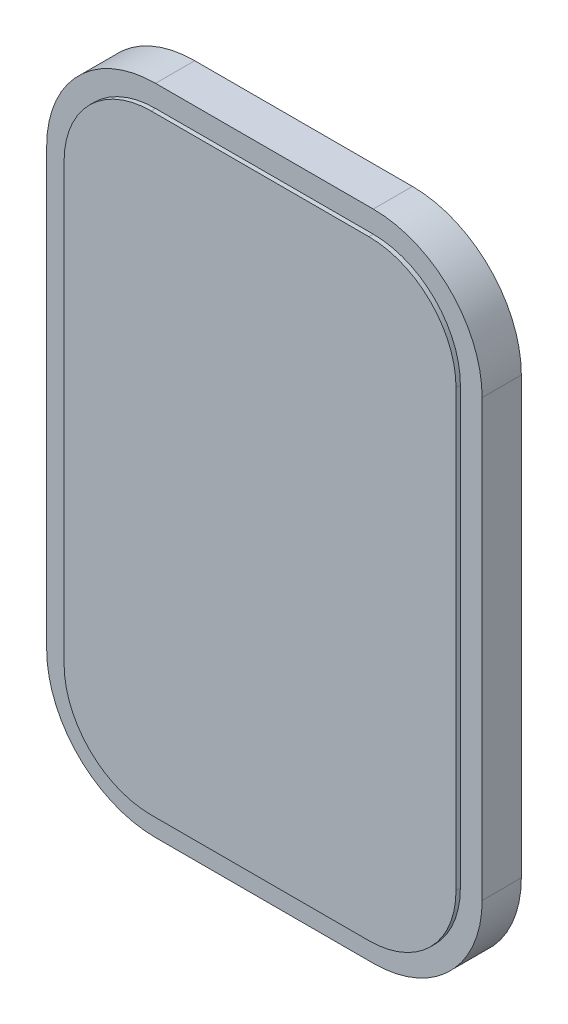
from build123d import *

# Parameters (mm, degrees)
SKETCH1_W           = 25.4
SKETCH1_H           = 38.1
BOSS_EXTRUDE1_DEPTH = 2.54
FILLET1_R           = 6.35
CUT_EXTRUDE1_DEPTH  = 0.254


with BuildPart() as part:
    # Sketch1 → Boss-Extrude1 (new body)
    with BuildSketch(Plane.XY):
        Rectangle(SKETCH1_W, SKETCH1_H)
    extrude(amount=BOSS_EXTRUDE1_DEPTH)

    # Fillet1
    fillet1_edges = [part.edges().sort_by_distance(p)[0] for p in [
        (12.7, -19.05, 1.27),
        (-12.7, -19.05, 1.27),
        (-12.7, 19.05, 1.27),
        (12.7, 19.05, 1.27),
    ]]
    fillet(fillet1_edges, radius=FILLET1_R)

    # Sketch2 → Cut-Extrude1 (cut)
    with BuildSketch(Plane.XY.offset(2.54)):
        with BuildLine():
            Line((-6.35, -19.05), (6.35, -19.05))
            ThreePointArc((6.35, -19.05), (10.840128061, -17.190128061), (12.7, -12.7))
            Line((12.7, -12.7), (12.7, 12.7))
            ThreePointArc((12.7, 12.7), (10.840128061, 17.190128061), (6.35, 19.05))
            Line((6.35, 19.05), (-6.35, 19.05))
            ThreePointArc((-6.35, 19.05), (-10.840128061, 17.190128061), (-12.7, 12.7))
            Line((-12.7, 12.7), (-12.7, -12.7))
            ThreePointArc((-12.7, -12.7), (-10.840128061, -17.190128061), (-6.35, -19.05))
        make_face()
        with BuildLine():
            Line((-11.43, 12.7), (-11.43, -12.7))
            ThreePointArc((-11.43, -12.7), (-9.942102448, -16.292102448), (-6.35, -17.78))
            Line((-6.35, -17.78), (6.35, -17.78))
            ThreePointArc((6.35, -17.78), (9.942102448, -16.292102448), (11.43, -12.7))
            Line((11.43, -12.7), (11.43, 12.7))
            ThreePointArc((11.43, 12.7), (9.942102448, 16.292102448), (6.35, 17.78))
            Line((6.35, 17.78), (-6.35, 17.78))
            ThreePointArc((-6.35, 17.78), (-9.942102448, 16.292102448), (-11.43, 12.7))
        make_face(mode=Mode.SUBTRACT)
    extrude(amount=-CUT_EXTRUDE1_DEPTH, mode=Mode.SUBTRACT)


solid = part.part
